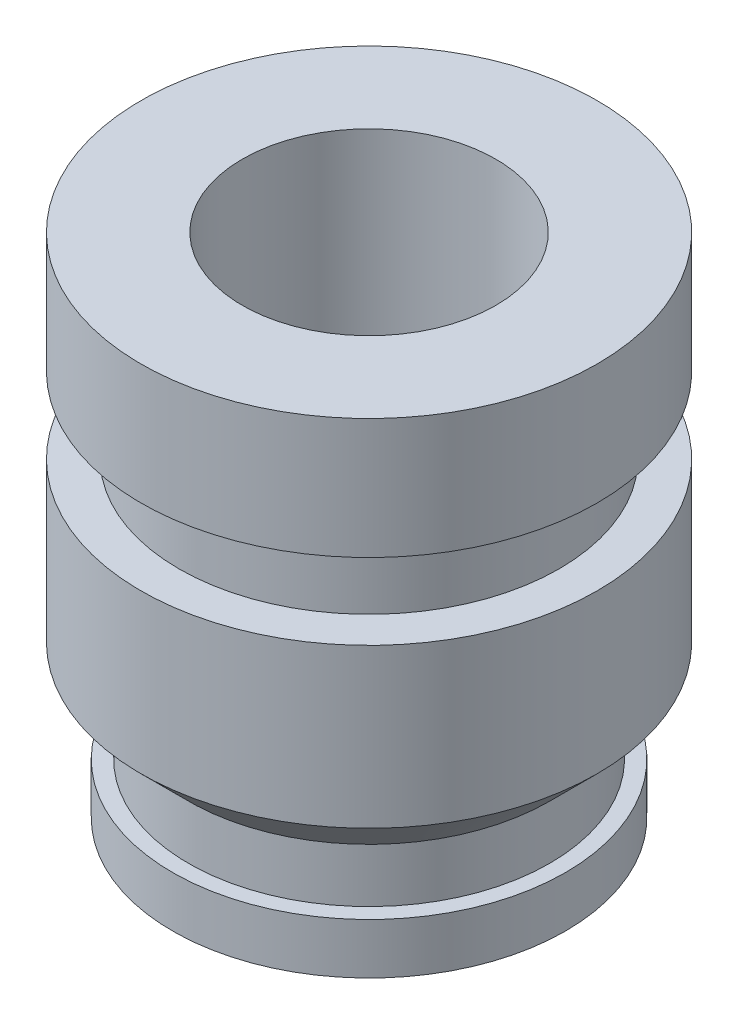
from build123d import *


with BuildPart() as part:
    # Sketch1 → Revolve1 (revolve)
    with BuildSketch(Plane.XY):
        Polygon((1, 0), (1, 4), (1.8, 4), (1.8, 3.05), (1.5, 3.05), (1.5, 2.45), (1.8, 2.45), (1.8, 1.2), (1.425, 0.825), (1.425, 0.4), (1.55, 0.4), (1.55, 0), align=None)
    revolve(axis=Axis((0, -1000, 0), (0, 1, 0)))


solid = part.part
